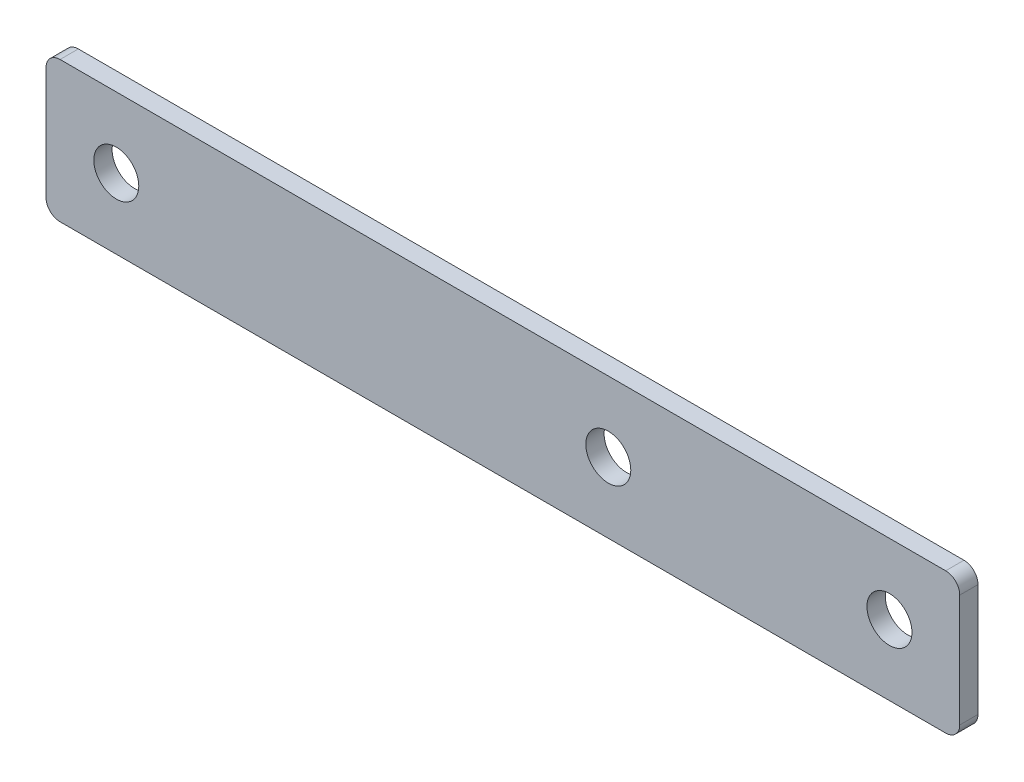
from build123d import *

# Parameters (mm, degrees)
SKETCH_1_W      = 65
SKETCH_1_H      = 10
SKETCH_1_R      = 1.6
EXTRUDE_1_DEPTH = 1.3
FILLET_1_R      = 1


with BuildPart() as part:
    # 草图1 → 凸台-拉伸1 (new body)
    with BuildSketch(Plane.XY):
        with Locations((32.5, 5)):
            Rectangle(SKETCH_1_W, SKETCH_1_H)
        with Locations((60, 5)):
            Circle(SKETCH_1_R, mode=Mode.SUBTRACT)
        with Locations((40, 5)):
            Circle(SKETCH_1_R, mode=Mode.SUBTRACT)
        with Locations((5, 5)):
            Circle(SKETCH_1_R, mode=Mode.SUBTRACT)
    extrude(amount=EXTRUDE_1_DEPTH)

    # 圆角1
    fillet_1_edges = [part.edges().sort_by_distance(p)[0] for p in [
        (0, 10, 0.65),
        (65, 10, 0.65),
        (65, 0, 0.65),
        (0, 0, 0.65),
    ]]
    fillet(fillet_1_edges, radius=FILLET_1_R)


solid = part.part
